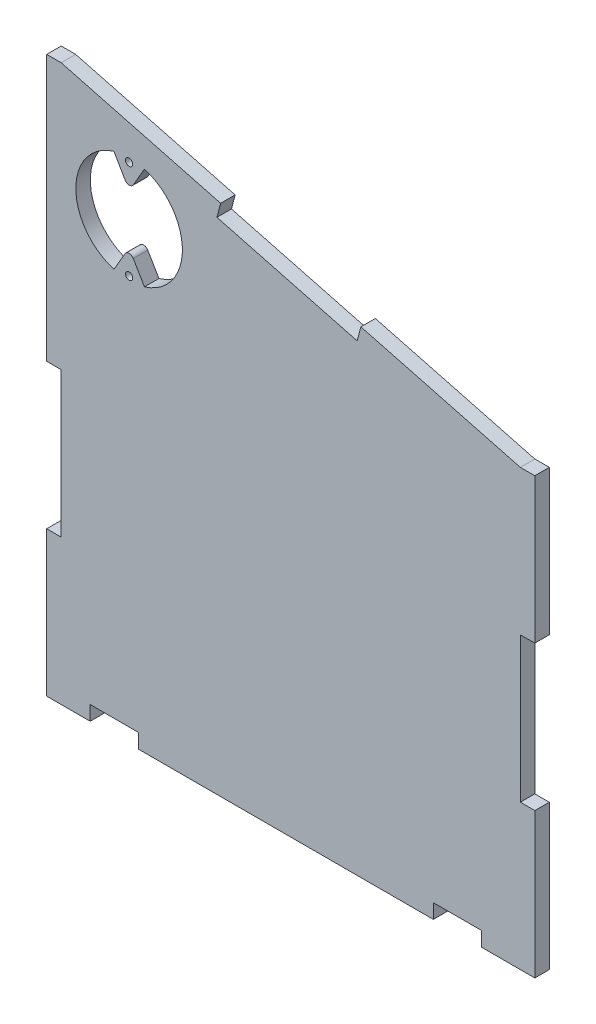
from build123d import *

# Parameters (mm, degrees)
MODEL_R             = 0.75
BOSS_EXTRUDE1_DEPTH = 3


with BuildPart() as part:
    # Model → Boss-Extrude1 (new body)
    with BuildSketch(Plane.XY):
        Polygon((403.601129512, 194.969765788), (403.601129512, 164.969765788), (406.601129512, 164.969765788), (406.601129512, 134.969765788), (395.601129512, 134.969765788), (395.601129512, 137.969765788), (385.601129512, 137.969765788), (385.601129512, 134.969765788), (324.601129512, 134.969765788), (324.601129512, 137.969765788), (314.601129512, 137.969765788), (314.601129512, 134.969765788), (305.601129512, 134.969765788), (305.601129512, 164.969765788), (308.601129512, 164.969765788), (308.601129512, 194.969765788), (305.601129512, 194.969765788), (305.601129512, 249.969765788), (308.601129512, 249.969765788), (341.595011453, 241.287165277), (340.831531555, 238.385941665), (369.843767673, 230.751142687), (370.607247571, 233.652366299), (403.601129512, 224.969765788), (406.601129512, 224.969765788), (406.601129512, 194.969765788), align=None)
        with Locations((322.652388944, 239.181914498)):
            Circle(MODEL_R, mode=Mode.SUBTRACT)
        with Locations((322.652388944, 218.781914498)):
            Circle(MODEL_R, mode=Mode.SUBTRACT)
        with BuildLine():
            Line((319.522778631, 239.551528485), (321.814644014, 235.581901198))
            ThreePointArc((321.814644014, 235.581901198), (322.680669418, 235.081901198), (323.546694821, 235.581901198))
            Line((323.546694821, 235.581901198), (325.830243575, 239.537123662))
            ThreePointArc((325.830243575, 239.537123662), (333.675600842, 228.981914498), (325.830243575, 218.426705335))
            Line((325.830243575, 218.426705335), (323.522241062, 222.353132192))
            ThreePointArc((323.522241062, 222.353132192), (322.656242047, 222.846375297), (321.794122171, 222.346382924))
            Line((321.794122171, 222.346382924), (319.522778631, 218.412300511))
            ThreePointArc((319.522778631, 218.412300511), (311.629177046, 228.981914498), (319.522778631, 239.551528485))
        make_face(mode=Mode.SUBTRACT)
    extrude(amount=BOSS_EXTRUDE1_DEPTH)


solid = part.part
